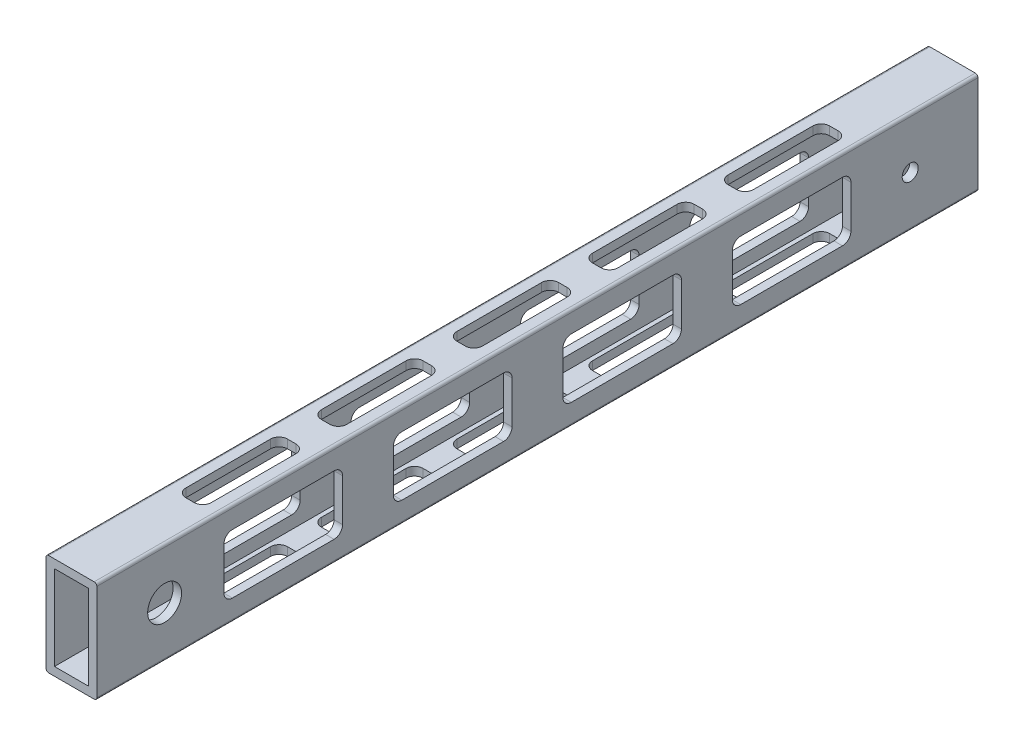
from build123d import *

# Parameters (mm, degrees)
SKETCH1_W               = 12.7
SKETCH1_H               = 31.75
BOSS_EXTRUDE1_DEPTH     = 165.1
CUT_EXTRUDE1_DEPTH      = 170.706645789
CUT_EXTRUDE1_DEPTH_BACK = 170.706645789
CUT_EXTRUDE2_DEPTH      = 168.283636378
CUT_EXTRUDE2_DEPTH_BACK = 168.283636378
SKETCH4_R               = 6.35
SKETCH4_R_2             = 3
CUT_EXTRUDE3_DEPTH      = 168.283636378
CUT_EXTRUDE3_DEPTH_BACK = 168.283636378


with BuildPart() as part:
    # Sketch1 → Boss-Extrude1 (new, symmetric)
    with BuildSketch(Plane.XY):
        with BuildLine():
            Line((-8.525, -19.05), (8.525, -19.05))
            ThreePointArc((8.525, -19.05), (9.232106781, -18.757106781), (9.525, -18.05))
            Line((9.525, -18.05), (9.525, 18.05))
            ThreePointArc((9.525, 18.05), (9.232106781, 18.757106781), (8.525, 19.05))
            Line((8.525, 19.05), (-8.525, 19.05))
            ThreePointArc((-8.525, 19.05), (-9.232106781, 18.757106781), (-9.525, 18.05))
            Line((-9.525, 18.05), (-9.525, -18.05))
            ThreePointArc((-9.525, -18.05), (-9.232106781, -18.757106781), (-8.525, -19.05))
        make_face()
        Rectangle(SKETCH1_W, SKETCH1_H, mode=Mode.SUBTRACT)
    extrude(amount=BOSS_EXTRUDE1_DEPTH, both=True)

    # Sketch2 → Cut-Extrude1 (cut, two sides)
    with BuildSketch(Plane(origin=(0, 19.05, 0), x_dir=(1, 0, 0), z_dir=(0, 1, 0))) as cut_extrude1_sk:
        with BuildLine():
            Line((-4.7625, -66.675), (-4.7625, -34.925))
            ThreePointArc((-4.7625, -34.925), (-3.83256403, -32.67993597), (-1.5875, -31.75))
            Line((-1.5875, -31.75), (1.5875, -31.75))
            ThreePointArc((1.5875, -31.75), (3.83256403, -32.67993597), (4.7625, -34.925))
            Line((4.7625, -34.925), (4.7625, -66.675))
            ThreePointArc((4.7625, -66.675), (3.83256403, -68.92006403), (1.5875, -69.85))
            Line((1.5875, -69.85), (-1.5875, -69.85))
            ThreePointArc((-1.5875, -69.85), (-3.83256403, -68.92006403), (-4.7625, -66.675))
        make_face()
        with BuildLine():
            Line((-1.5875, -120.65), (1.5875, -120.65))
            ThreePointArc((1.5875, -120.65), (3.83256403, -119.72006403), (4.7625, -117.475))
            Line((4.7625, -117.475), (4.7625, -85.725))
            ThreePointArc((4.7625, -85.725), (3.83256403, -83.47993597), (1.5875, -82.55))
            Line((1.5875, -82.55), (-1.5875, -82.55))
            ThreePointArc((-1.5875, -82.55), (-3.83256403, -83.47993597), (-4.7625, -85.725))
            Line((-4.7625, -85.725), (-4.7625, -117.475))
            ThreePointArc((-4.7625, -117.475), (-3.83256403, -119.72006403), (-1.5875, -120.65))
        make_face()
        with BuildLine():
            Line((-4.7625, -15.875), (-4.7625, 15.875))
            ThreePointArc((-4.7625, 15.875), (-3.83256403, 18.12006403), (-1.5875, 19.05))
            Line((-1.5875, 19.05), (1.5875, 19.05))
            ThreePointArc((1.5875, 19.05), (3.83256403, 18.12006403), (4.7625, 15.875))
            Line((4.7625, 15.875), (4.7625, -15.875))
            ThreePointArc((4.7625, -15.875), (3.83256403, -18.12006403), (1.5875, -19.05))
            Line((1.5875, -19.05), (-1.5875, -19.05))
            ThreePointArc((-1.5875, -19.05), (-3.83256403, -18.12006403), (-4.7625, -15.875))
        make_face()
        with BuildLine():
            Line((-4.7625, 34.925), (-4.7625, 66.675))
            ThreePointArc((-4.7625, 66.675), (-3.83256403, 68.92006403), (-1.5875, 69.85))
            Line((-1.5875, 69.85), (1.5875, 69.85))
            ThreePointArc((1.5875, 69.85), (3.83256403, 68.92006403), (4.7625, 66.675))
            Line((4.7625, 66.675), (4.7625, 34.925))
            ThreePointArc((4.7625, 34.925), (3.83256403, 32.67993597), (1.5875, 31.75))
            Line((1.5875, 31.75), (-1.5875, 31.75))
            ThreePointArc((-1.5875, 31.75), (-3.83256403, 32.67993597), (-4.7625, 34.925))
        make_face()
        with BuildLine():
            Line((-4.7625, 85.725), (-4.7625, 117.475))
            ThreePointArc((-4.7625, 117.475), (-3.83256403, 119.72006403), (-1.5875, 120.65))
            Line((-1.5875, 120.65), (1.5875, 120.65))
            ThreePointArc((1.5875, 120.65), (3.83256403, 119.72006403), (4.7625, 117.475))
            Line((4.7625, 117.475), (4.7625, 85.725))
            ThreePointArc((4.7625, 85.725), (3.83256403, 83.47993597), (1.5875, 82.55))
            Line((1.5875, 82.55), (-1.5875, 82.55))
            ThreePointArc((-1.5875, 82.55), (-3.83256403, 83.47993597), (-4.7625, 85.725))
        make_face()
    extrude(amount=CUT_EXTRUDE1_DEPTH, mode=Mode.SUBTRACT)
    extrude(cut_extrude1_sk.sketch, amount=-CUT_EXTRUDE1_DEPTH_BACK, mode=Mode.SUBTRACT)

    # Sketch3 → Cut-Extrude2 (cut, two sides)
    with BuildSketch(Plane(origin=(9.525, 0, 0), x_dir=(0, 0, -1), z_dir=(1, 0, 0))) as cut_extrude2_sk:
        with BuildLine():
            Line((-53.975, -7.9375), (-53.975, 7.9375))
            ThreePointArc((-53.975, 7.9375), (-53.04506403, 10.18256403), (-50.8, 11.1125))
            Line((-50.8, 11.1125), (-12.7, 11.1125))
            ThreePointArc((-12.7, 11.1125), (-10.45493597, 10.18256403), (-9.525, 7.9375))
            Line((-9.525, 7.9375), (-9.525, -7.9375))
            ThreePointArc((-9.525, -7.9375), (-10.45493597, -10.18256403), (-12.7, -11.1125))
            Line((-12.7, -11.1125), (-50.8, -11.1125))
            ThreePointArc((-50.8, -11.1125), (-53.04506403, -10.18256403), (-53.975, -7.9375))
        make_face()
        with BuildLine():
            Line((-114.3, -11.1125), (-76.2, -11.1125))
            ThreePointArc((-76.2, -11.1125), (-73.95493597, -10.18256403), (-73.025, -7.9375))
            Line((-73.025, -7.9375), (-73.025, 7.9375))
            ThreePointArc((-73.025, 7.9375), (-73.95493597, 10.18256403), (-76.2, 11.1125))
            Line((-76.2, 11.1125), (-114.3, 11.1125))
            ThreePointArc((-114.3, 11.1125), (-116.54506403, 10.18256403), (-117.475, 7.9375))
            Line((-117.475, 7.9375), (-117.475, -7.9375))
            ThreePointArc((-117.475, -7.9375), (-116.54506403, -10.18256403), (-114.3, -11.1125))
        make_face()
        with BuildLine():
            Line((9.525, -7.9375), (9.525, 7.9375))
            ThreePointArc((9.525, 7.9375), (10.45493597, 10.18256403), (12.7, 11.1125))
            Line((12.7, 11.1125), (50.8, 11.1125))
            ThreePointArc((50.8, 11.1125), (53.04506403, 10.18256403), (53.975, 7.9375))
            Line((53.975, 7.9375), (53.975, -7.9375))
            ThreePointArc((53.975, -7.9375), (53.04506403, -10.18256403), (50.8, -11.1125))
            Line((50.8, -11.1125), (12.7, -11.1125))
            ThreePointArc((12.7, -11.1125), (10.45493597, -10.18256403), (9.525, -7.9375))
        make_face()
        with BuildLine():
            Line((73.025, -7.9375), (73.025, 7.9375))
            ThreePointArc((73.025, 7.9375), (73.95493597, 10.18256403), (76.2, 11.1125))
            Line((76.2, 11.1125), (114.3, 11.1125))
            ThreePointArc((114.3, 11.1125), (116.54506403, 10.18256403), (117.475, 7.9375))
            Line((117.475, 7.9375), (117.475, -7.9375))
            ThreePointArc((117.475, -7.9375), (116.54506403, -10.18256403), (114.3, -11.1125))
            Line((114.3, -11.1125), (76.2, -11.1125))
            ThreePointArc((76.2, -11.1125), (73.95493597, -10.18256403), (73.025, -7.9375))
        make_face()
    extrude(amount=CUT_EXTRUDE2_DEPTH, mode=Mode.SUBTRACT)
    extrude(cut_extrude2_sk.sketch, amount=-CUT_EXTRUDE2_DEPTH_BACK, mode=Mode.SUBTRACT)

    # Sketch4 → Cut-Extrude3 (cut, two sides)
    with BuildSketch(Plane(origin=(9.525, 0, 0), x_dir=(0, 0, -1), z_dir=(1, 0, 0))) as cut_extrude3_sk:
        with Locations((-139.7, 0)):
            Circle(SKETCH4_R)
        with Locations((139.7, 0)):
            Circle(SKETCH4_R_2)
    extrude(amount=CUT_EXTRUDE3_DEPTH, mode=Mode.SUBTRACT)
    extrude(cut_extrude3_sk.sketch, amount=-CUT_EXTRUDE3_DEPTH_BACK, mode=Mode.SUBTRACT)


solid = part.part
